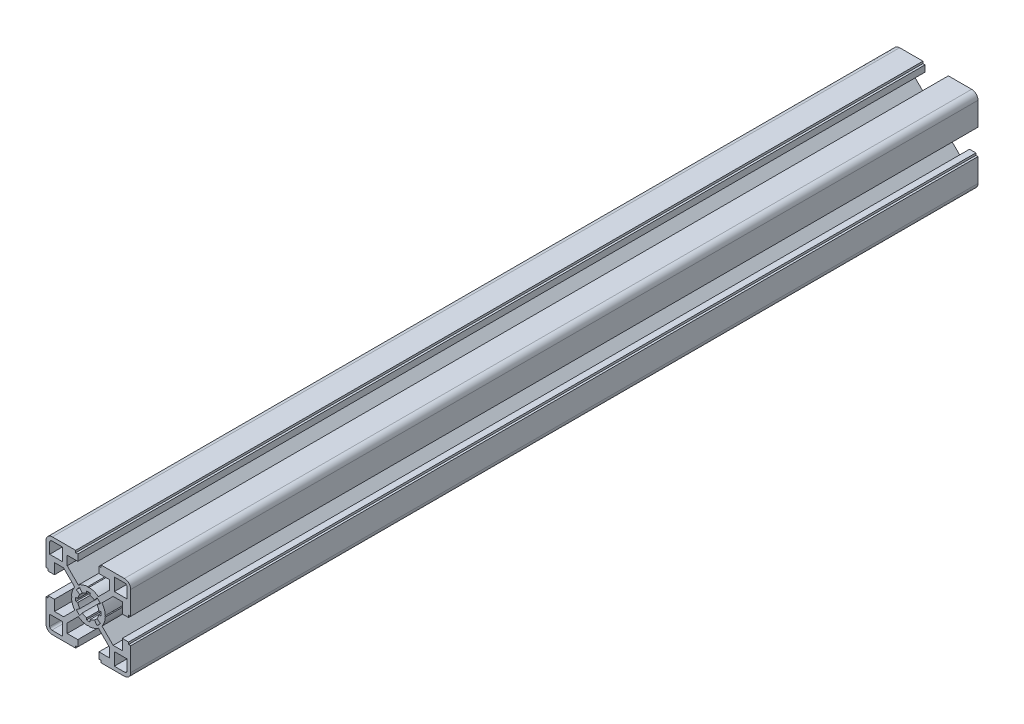
from build123d import *

# Parameters (mm, degrees)
BOSS_EXTRU_1_DEPTH = 400


with BuildPart() as part:
    # Esquisse1 → Boss.-Extru.1 (new body)
    with BuildSketch(Plane.XY.offset(100)):
        with BuildLine():
            Line((6, -19), (6, -20))
            Line((6, -20), (17, -20))
            ThreePointArc((17, -20), (19.121320344, -19.121320344), (20, -17))
            Line((20, -17), (20, -6))
            Line((20, -6), (19, -6))
            Line((19, -6), (19, -5))
            Line((19, -5), (16, -5))
            Line((16, -5), (16, -10))
            Line((16, -10), (11.697056276, -10))
            Line((11.697056276, -10), (6.44138072, -4.744324444))
            ThreePointArc((6.44138072, -4.744324444), (7.551143817, -2.642011933), (7.994130058, -0.306405969))
            Line((7.994130058, -0.306405969), (7.7, 0))
            Line((7.7, 0), (7.994130058, 0.306405971))
            ThreePointArc((7.994130058, 0.306405971), (7.551143817, 2.642011934), (6.441380719, 4.744324444))
            Line((6.441380719, 4.744324444), (11.697056275, 10))
            Line((11.697056275, 10), (16, 10))
            Line((16, 10), (16, 5))
            Line((16, 5), (19, 5))
            Line((19, 5), (19, 6))
            Line((19, 6), (20, 6))
            Line((20, 6), (20, 17))
            ThreePointArc((20, 17), (19.121320344, 19.121320344), (17, 20))
            Line((17, 20), (6, 20))
            Line((6, 20), (6, 19))
            Line((6, 19), (5, 19))
            Line((5, 19), (5, 15.999999999))
            Line((5, 15.999999999), (10.000000001, 15.999999999))
            Line((10.000000001, 15.999999999), (10.000000001, 11.697056275))
            Line((10.000000001, 11.697056275), (4.744324444, 6.441380719))
            ThreePointArc((4.744324444, 6.441380719), (2.642011933, 7.551143817), (0.306405969, 7.994130058))
            Line((0.306405969, 7.994130058), (0, 7.7))
            Line((0, 7.7), (-0.30640597, 7.994130058))
            ThreePointArc((-0.30640597, 7.994130058), (-2.642011933, 7.551143817), (-4.744324444, 6.441380719))
            Line((-4.744324444, 6.441380719), (-9.999999999, 11.697056274))
            Line((-9.999999999, 11.697056274), (-9.999999999, 15.999999999))
            Line((-9.999999999, 15.999999999), (-5, 15.999999999))
            Line((-5, 15.999999999), (-5, 19))
            Line((-5, 19), (-6, 19))
            Line((-6, 19), (-6, 20))
            Line((-6, 20), (-17, 20))
            ThreePointArc((-17, 20), (-19.121320344, 19.121320344), (-20, 17))
            Line((-20, 17), (-20, 6))
            Line((-20, 6), (-19, 6))
            Line((-19, 6), (-19, 5))
            Line((-19, 5), (-16, 5))
            Line((-16, 5), (-16, 10))
            Line((-16, 10), (-11.697056274, 10))
            Line((-11.697056274, 10), (-6.441380718, 4.744324445))
            ThreePointArc((-6.441380718, 4.744324445), (-7.551143817, 2.642011933), (-7.994130058, 0.306405969))
            Line((-7.994130058, 0.306405969), (-7.699999999, 0))
            Line((-7.699999999, 0), (-7.994130057, -0.306405971))
            ThreePointArc((-7.994130057, -0.306405971), (-7.551143816, -2.642011934), (-6.441380719, -4.744324444))
            Line((-6.441380719, -4.744324444), (-11.697056275, -10))
            Line((-11.697056275, -10), (-16, -10))
            Line((-16, -10), (-16, -5))
            Line((-16, -5), (-19, -5))
            Line((-19, -5), (-19, -6))
            Line((-19, -6), (-20, -6))
            Line((-20, -6), (-20, -17))
            ThreePointArc((-20, -17), (-19.121320344, -19.121320344), (-17, -20))
            Line((-17, -20), (-6, -20))
            Line((-6, -20), (-6, -19))
            Line((-6, -19), (-5, -19))
            Line((-5, -19), (-5, -16.000000001))
            Line((-5, -16.000000001), (-9.999999999, -16.000000001))
            Line((-9.999999999, -16.000000001), (-9.999999999, -11.697056274))
            Line((-9.999999999, -11.697056274), (-4.744324444, -6.441380719))
            ThreePointArc((-4.744324444, -6.441380719), (-2.642011933, -7.551143817), (-0.306405969, -7.994130058))
            Line((-0.306405969, -7.994130058), (0, -7.7))
            Line((0, -7.7), (0.306405971, -7.994130058))
            ThreePointArc((0.306405971, -7.994130058), (2.642011934, -7.551143817), (4.744324445, -6.441380719))
            Line((4.744324445, -6.441380719), (10.000000001, -11.697056274))
            Line((10.000000001, -11.697056274), (10.000000001, -16.000000001))
            Line((10.000000001, -16.000000001), (5, -16.000000001))
            Line((5, -16.000000001), (5, -19))
            Line((5, -19), (6, -19))
        make_face()
        with BuildLine():
            Line((18.25, 12.25), (12.25, 12.25))
            Line((12.25, 12.25), (12.25, 18.25))
            Line((12.25, 18.25), (17.25, 18.25))
            ThreePointArc((17.25, 18.25), (17.957106781, 17.957106781), (18.25, 17.25))
            Line((18.25, 17.25), (18.25, 12.25))
        make_face(mode=Mode.SUBTRACT)
        with BuildLine():
            Line((-18.25, -12.25), (-12.25, -12.25))
            Line((-12.25, -12.25), (-12.25, -18.25))
            Line((-12.25, -18.25), (-17.25, -18.25))
            ThreePointArc((-17.25, -18.25), (-17.957106781, -17.957106781), (-18.25, -17.25))
            Line((-18.25, -17.25), (-18.25, -12.25))
        make_face(mode=Mode.SUBTRACT)
        with BuildLine():
            Line((-12.25, 18.25), (-12.25, 12.25))
            Line((-12.25, 12.25), (-18.25, 12.25))
            Line((-18.25, 12.25), (-18.25, 17.25))
            ThreePointArc((-18.25, 17.25), (-17.957106781, 17.957106781), (-17.25, 18.25))
            Line((-17.25, 18.25), (-12.25, 18.25))
        make_face(mode=Mode.SUBTRACT)
        with BuildLine():
            Line((12.25, -18.25), (12.25, -12.25))
            Line((12.25, -12.25), (18.25, -12.25))
            Line((18.25, -12.25), (18.25, -17.25))
            ThreePointArc((18.25, -17.25), (17.957106781, -17.957106781), (17.25, -18.25))
            Line((17.25, -18.25), (12.25, -18.25))
        make_face(mode=Mode.SUBTRACT)
        with BuildLine():
            Line((-5.705709703, -4.055228326), (-4.075506937, -2.896591666))
            ThreePointArc((-4.075506937, -2.896591666), (-4.635549589, -1.873947727), (-4.943520622, -0.749402378))
            Line((-4.943520622, -0.749402378), (-5.932224738, -0.899282852))
            ThreePointArc((-5.932224738, -0.899282852), (-6, 0), (-5.932224738, 0.899282853))
            Line((-5.932224738, 0.899282853), (-4.943520622, 0.749402379))
            ThreePointArc((-4.943520622, 0.749402379), (-4.635549588, 1.873947727), (-4.075506937, 2.896591666))
            Line((-4.075506937, 2.896591666), (-5.705709704, 4.055228326))
            ThreePointArc((-5.705709704, 4.055228326), (-4.953610357, 4.945881563), (-4.064132573, 5.699370705))
            Line((-4.064132573, 5.699370705), (-2.902951842, 4.070979081))
            ThreePointArc((-2.902951842, 4.070979081), (-1.877566249, 4.634085136), (-0.749402377, 4.943520623))
            Line((-0.749402377, 4.943520623), (-0.899282852, 5.932224739))
            ThreePointArc((-0.899282852, 5.932224739), (0, 6), (0.899282852, 5.932224739))
            Line((0.899282852, 5.932224739), (0.749402377, 4.943520623))
            ThreePointArc((0.749402377, 4.943520623), (1.87756625, 4.634085136), (2.902951843, 4.07097908))
            Line((2.902951843, 4.07097908), (4.064132575, 5.699370704))
            ThreePointArc((4.064132575, 5.699370704), (4.953610358, 4.945881562), (5.705709704, 4.055228326))
            Line((5.705709704, 4.055228326), (4.075506937, 2.896591666))
            ThreePointArc((4.075506937, 2.896591666), (4.635549589, 1.873947727), (4.943520623, 0.749402378))
            Line((4.943520623, 0.749402378), (5.932224739, 0.899282853))
            ThreePointArc((5.932224739, 0.899282853), (6, 0), (5.932224739, -0.899282853))
            Line((5.932224739, -0.899282853), (4.943520623, -0.749402379))
            ThreePointArc((4.943520623, -0.749402379), (4.635549589, -1.873947727), (4.075506938, -2.896591666))
            Line((4.075506938, -2.896591666), (5.705709704, -4.055228326))
            ThreePointArc((5.705709704, -4.055228326), (4.953610357, -4.945881563), (4.064132573, -5.699370705))
            Line((4.064132573, -5.699370705), (2.902951842, -4.070979081))
            ThreePointArc((2.902951842, -4.070979081), (1.87756625, -4.634085136), (0.749402378, -4.943520623))
            Line((0.749402378, -4.943520623), (0.899282852, -5.932224739))
            ThreePointArc((0.899282852, -5.932224739), (1e-09, -6), (-0.899282851, -5.932224739))
            Line((-0.899282851, -5.932224739), (-0.749402377, -4.943520623))
            ThreePointArc((-0.749402377, -4.943520623), (-1.87756625, -4.634085136), (-2.902951843, -4.07097908))
            Line((-2.902951843, -4.07097908), (-4.064132574, -5.699370704))
            ThreePointArc((-4.064132574, -5.699370704), (-4.953610357, -4.945881562), (-5.705709703, -4.055228326))
        make_face(mode=Mode.SUBTRACT)
    extrude(amount=-BOSS_EXTRU_1_DEPTH)


solid = part.part
